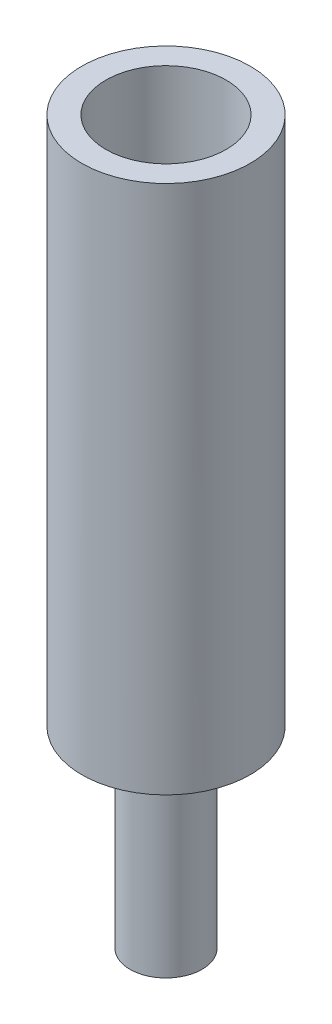
from build123d import *

# Parameters (mm, degrees)
SKETCH1_R           = 3.5
BOSS_EXTRUDE1_DEPTH = 30
SKETCH2_R           = 2.5
CUT_EXTRUDE1_DEPTH  = 20
SKETCH3_R           = 3.5
SKETCH3_R_2         = 1.5
CUT_EXTRUDE4_DEPTH  = 8


with BuildPart() as part:
    # Sketch1 → Boss-Extrude1 (new body)
    with BuildSketch(Plane(origin=(0, 0, 0), x_dir=(1, 0, 0), z_dir=(0, 1, 0))):
        Circle(SKETCH1_R)
    extrude(amount=BOSS_EXTRUDE1_DEPTH)

    # Sketch2 → Cut-Extrude1 (cut)
    with BuildSketch(Plane(origin=(0, 30, 0), x_dir=(1, 0, 0), z_dir=(0, 1, 0))):
        Circle(SKETCH2_R)
    extrude(amount=-CUT_EXTRUDE1_DEPTH, mode=Mode.SUBTRACT)

    # Sketch3 → Cut-Extrude4 (cut)
    with BuildSketch(Plane.XZ):
        Circle(SKETCH3_R)
        Circle(SKETCH3_R_2, mode=Mode.SUBTRACT)
    extrude(amount=-CUT_EXTRUDE4_DEPTH, mode=Mode.SUBTRACT)


solid = part.part
